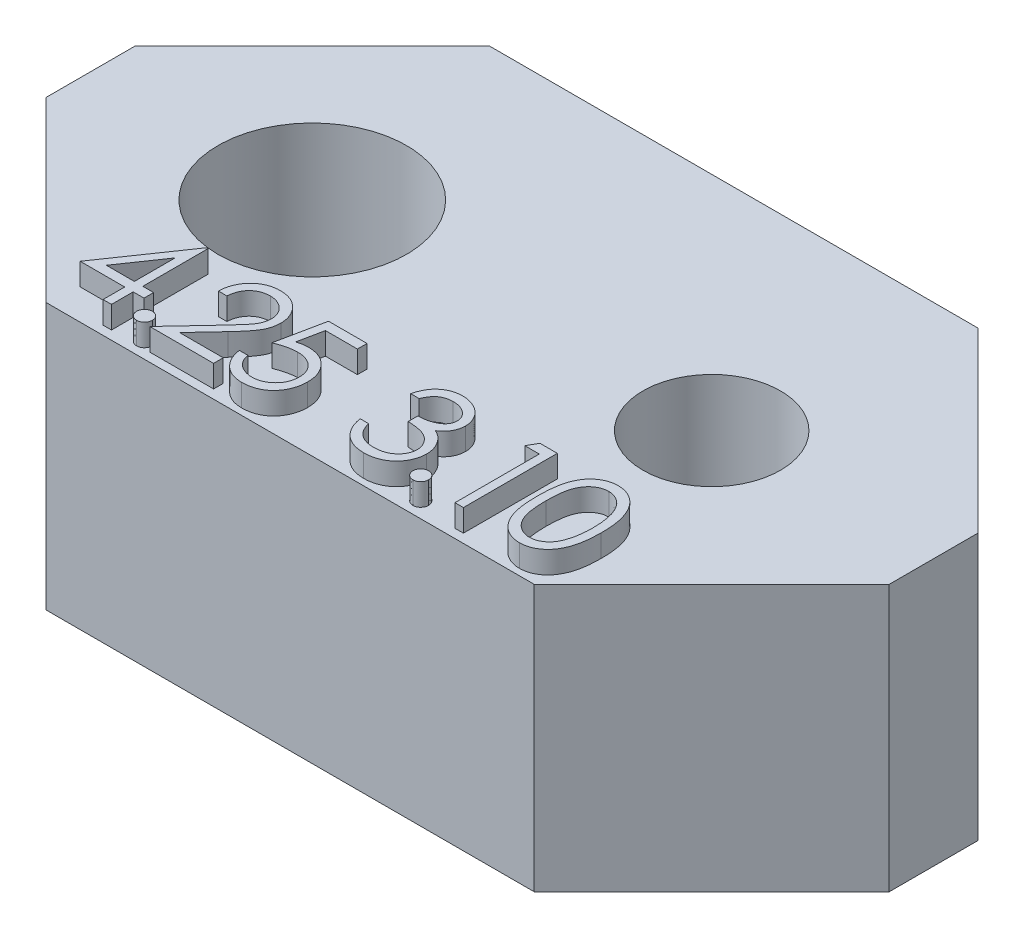
from build123d import *

# Parameters (mm, degrees)
SKETCH_1_R      = 2.125
SKETCH_1_R_2    = 1.55
EXTRUDE_1_DEPTH = 6
SKETCH_1_3_R    = 2.125
SKETCH_1_3_R_2  = 1.55
EXTRUDE_2_DEPTH = 2
EXTRUDE_3_DEPTH = 0.5


with BuildPart() as part:
    # Эскиз1 → Бобышка-Вытянуть1 (new body)
    with BuildSketch(Plane(origin=(0, 0, 0), x_dir=(1, 0, 0), z_dir=(0, 1, 0))):
        Polygon((9.5, 1), (5.5, 5), (-5.5, 5), (-9.5, 1), (-9.5, -1), (-5.5, -5), (5.5, -5), (9.5, -1), align=None)
        with Locations((-4.5, 0)):
            Circle(SKETCH_1_R, mode=Mode.SUBTRACT)
        with Locations((4.5, 0)):
            Circle(SKETCH_1_R_2, mode=Mode.SUBTRACT)
    extrude(amount=EXTRUDE_1_DEPTH)

    # Эскиз1<3> → Бобышка-Вытянуть2 (add)
    with BuildSketch(Plane(origin=(0, 0, 0), x_dir=(1, 0, 0), z_dir=(0, 1, 0))):
        with Locations((-4.5, 0)):
            Circle(SKETCH_1_3_R)
        with Locations((4.5, 0)):
            Circle(SKETCH_1_3_R_2)
    extrude(amount=EXTRUDE_2_DEPTH)

    # Эскиз3 → Бобышка-Вытянуть3 (add)
    # profile 1 of 8: a face of its own
    with BuildSketch(Plane(origin=(0, 6, 0), x_dir=(1, 0, 0), z_dir=(0, 1, 0))):
        Polygon((-4.263157719, -2.629059829), (-4.22457265, -2.629059829), (-4.22457265, -4.094444444), (-3.98034188, -4.094444444), (-3.98034188, -4.311538462), (-4.22457265, -4.311538462), (-4.22457265, -4.8), (-4.414529915, -4.8), (-4.414529915, -4.311538462), (-5.418589744, -4.311538462), align=None)
        Polygon((-4.414529915, -4.094444444), (-4.414529915, -3.175186966), (-5.045459402, -4.094444444), align=None, mode=Mode.SUBTRACT)
    # profile 2 of 8: a face of its own
    with BuildSketch(Plane(origin=(0, 6, 0), x_dir=(1, 0, 0), z_dir=(0, 1, 0))):
        with BuildLine():
            add(Edge.make_bspline(
                [(-3.630277778, -4.474358974), (-3.61849084, -4.475059389), (-3.595383926, -4.476432471), (-3.561977406, -4.48585265), (-3.53174254, -4.502579554), (-3.504811135, -4.524872758), (-3.482612456, -4.551902993), (-3.465289443, -4.581896709), (-3.455951324, -4.61558291), (-3.454588244, -4.638823714), (-3.453888889, -4.650747863)],
                knots=[0, 0, 0, 0, 1.020151414, 1.999887582, 2.974338812, 3.990962822, 5.007586832, 5.987933904, 6.967670073, 8, 8, 8, 8], degree=3))
            add(Edge.make_bspline(
                [(-3.453888889, -4.650747863), (-3.454611943, -4.662385496), (-3.456037794, -4.685334737), (-3.465268038, -4.71876686), (-3.482744478, -4.748779321), (-3.504658021, -4.776176328), (-3.531749198, -4.798516759), (-3.562048886, -4.815101354), (-3.595305504, -4.825196027), (-3.618477757, -4.826481931), (-3.630277778, -4.827136752)],
                knots=[0, 0, 0, 0, 1.009421747, 1.99056486, 2.972319754, 3.999869655, 5.017953583, 5.993804169, 6.978383603, 8, 8, 8, 8], degree=3))
            add(Edge.make_bspline(
                [(-3.630277778, -4.827136752), (-3.642086302, -4.826505624), (-3.665139634, -4.825273498), (-3.698272116, -4.814894086), (-3.72875633, -4.798672279), (-3.755842232, -4.776134672), (-3.777939308, -4.7489203), (-3.794646087, -4.718560166), (-3.804679177, -4.685430439), (-3.80599869, -4.662404346), (-3.806666667, -4.650747863)],
                knots=[0, 0, 0, 0, 1.022052826, 1.995314843, 2.982371812, 4.00089066, 5.028879526, 6.005146991, 6.990147033, 8, 8, 8, 8], degree=3))
            add(Edge.make_bspline(
                [(-3.806666667, -4.650747863), (-3.806024349, -4.638804191), (-3.804770304, -4.615485636), (-3.794625024, -4.582103319), (-3.778068934, -4.551763358), (-3.755689481, -4.524913998), (-3.728762883, -4.502424534), (-3.698345654, -4.486056778), (-3.665059837, -4.476356147), (-3.642072874, -4.475036244), (-3.630277778, -4.474358974)],
                knots=[0, 0, 0, 0, 1.032775665, 2.016367738, 2.991239715, 4.008302682, 5.025365648, 6.011011707, 6.979408107, 8, 8, 8, 8], degree=3))
        make_face()
    # profile 3 of 8: a face of its own
    with BuildSketch(Plane(origin=(0, 6, 0), x_dir=(1, 0, 0), z_dir=(0, 1, 0))):
        with BuildLine():
            Line((-3.09025641, -3.334615385), (-3.280213675, -3.334615385))
            add(Edge.make_bspline(
                [(-3.280213675, -3.334615385), (-3.278975635, -3.309414419), (-3.276544157, -3.259920394), (-3.265157525, -3.187757841), (-3.248864709, -3.118781843), (-3.225828449, -3.053546229), (-3.197219414, -2.991474188), (-3.162911255, -2.932812274), (-3.122274973, -2.877784269), (-3.076188044, -2.826900302), (-3.026132724, -2.7802202), (-2.972123894, -2.739909648), (-2.915369997, -2.705850866), (-2.856043217, -2.677377925), (-2.79347421, -2.656005732), (-2.728230767, -2.640147883), (-2.660026242, -2.63060695), (-2.613556324, -2.629581404), (-2.589922543, -2.629059829)],
                knots=[0, 0, 0, 0, 1.10065271, 2.161652631, 3.183658789, 4.190468796, 5.17591951, 6.163126047, 7.15150782, 8.156236427, 9.156009102, 10.134482811, 11.092018607, 12.041330605, 13.001268258, 13.972401359, 14.968799086, 16, 16, 16, 16], degree=3))
            add(Edge.make_bspline(
                [(-2.589922543, -2.629059829), (-2.566712946, -2.629603181), (-2.521106916, -2.630670849), (-2.454545603, -2.639839662), (-2.391180286, -2.654200091), (-2.331134828, -2.674347986), (-2.274888303, -2.701431901), (-2.222018176, -2.733966603), (-2.171895019, -2.771594787), (-2.126775678, -2.815895903), (-2.085344602, -2.863189726), (-2.04960181, -2.913680029), (-2.018992896, -2.965828217), (-1.993479395, -3.020031938), (-1.974697825, -3.07680156), (-1.960438623, -3.135310583), (-1.952378711, -3.196164635), (-1.951141717, -3.237352886), (-1.950512821, -3.258293269)],
                knots=[0, 0, 0, 0, 1.111607364, 2.184268762, 3.212621178, 4.221274766, 5.211760367, 6.196651075, 7.1921475, 8.207485113, 9.220403448, 10.201281604, 11.166441695, 12.114753415, 13.065576456, 14.026450734, 14.996634279, 16, 16, 16, 16], degree=3))
            add(Edge.make_bspline(
                [(-1.950512821, -3.258293269), (-1.951536841, -3.287774103), (-1.953566913, -3.346218422), (-1.970932274, -3.432103601), (-1.998053736, -3.515314859), (-2.03070928, -3.582284561), (-2.063652139, -3.636249579), (-2.093338394, -3.680680653), (-2.128090922, -3.728520626), (-2.168415538, -3.779609302), (-2.213478084, -3.834346849), (-2.263686726, -3.892700202), (-2.319399498, -3.954066462), (-2.358502496, -3.99597985), (-2.37876469, -4.017698317)],
                knots=[0, 0, 0, 0, 1.184426356, 2.348067706, 3.509069118, 4.696110526, 5.333549288, 6.050745305, 6.844228056, 7.710549037, 8.667450064, 9.695053472, 10.805634456, 12, 12, 12, 12], degree=3))
            Line((-2.37876469, -4.017698317), (-2.908355369, -4.582905983))
            Line((-2.908355369, -4.582905983), (-1.923376068, -4.582905983))
            Line((-1.923376068, -4.582905983), (-1.923376068, -4.8))
            Line((-1.923376068, -4.8), (-3.361623932, -4.8))
            Line((-3.361623932, -4.8), (-2.540737179, -3.92399172))
            add(Edge.make_bspline(
                [(-2.540737179, -3.92399172), (-2.520751077, -3.903128459), (-2.482361863, -3.863054403), (-2.428064781, -3.804547946), (-2.379297393, -3.750270843), (-2.335744017, -3.700325644), (-2.298349469, -3.653981791), (-2.265164833, -3.612740233), (-2.238576118, -3.574788732), (-2.209719665, -3.53079798), (-2.181771209, -3.477087673), (-2.157754689, -3.411450633), (-2.143110472, -3.343882247), (-2.141353738, -3.298221491), (-2.140470085, -3.275253739)],
                knots=[0, 0, 0, 0, 1.329631726, 2.553950428, 3.673215718, 4.687767853, 5.603093632, 6.413772471, 7.123043292, 7.734684054, 8.834405432, 9.900288307, 10.943827018, 12, 12, 12, 12], degree=3))
            add(Edge.make_bspline(
                [(-2.140470085, -3.275253739), (-2.140854558, -3.260811179), (-2.14161228, -3.232347667), (-2.148299554, -3.190615613), (-2.158405432, -3.150359749), (-2.172886612, -3.111456251), (-2.192001164, -3.074296261), (-2.215268399, -3.038834547), (-2.242113818, -3.004551221), (-2.273169109, -2.972406131), (-2.307284647, -2.942965592), (-2.343324979, -2.916885788), (-2.38145528, -2.895090707), (-2.421514783, -2.877223925), (-2.463391805, -2.863208338), (-2.507167341, -2.85349672), (-2.552720437, -2.847399218), (-2.583825456, -2.846574219), (-2.599674813, -2.846153846)],
                knots=[0, 0, 0, 0, 0.991446411, 1.95395049, 2.89581595, 3.838931463, 4.798493298, 5.75982156, 6.748411868, 7.785213223, 8.824556874, 9.840280684, 10.836137867, 11.835679398, 12.848801643, 13.863922112, 14.911575587, 16, 16, 16, 16], degree=3))
            add(Edge.make_bspline(
                [(-2.599674813, -2.846153846), (-2.61622765, -2.84658627), (-2.648734689, -2.84743548), (-2.696461913, -2.853375853), (-2.741991884, -2.863624052), (-2.78543913, -2.877640422), (-2.826877165, -2.89545583), (-2.866104468, -2.917645599), (-2.903032977, -2.944124188), (-2.937732112, -2.974144905), (-2.969702233, -3.007568645), (-2.997791534, -3.044828004), (-3.0223352, -3.085242679), (-3.043749355, -3.128703621), (-3.061139701, -3.175605193), (-3.074428226, -3.2257809), (-3.084943128, -3.279012878), (-3.0884559, -3.315773382), (-3.09025641, -3.334615385)],
                knots=[0, 0, 0, 0, 1.031018746, 2.02475058, 2.990194455, 3.934040569, 4.864654155, 5.795059489, 6.735614925, 7.690564532, 8.649604399, 9.611025574, 10.590972636, 11.591080095, 12.624614302, 13.701020113, 14.821632451, 16, 16, 16, 16], degree=3))
        make_face()
    # profile 4 of 8: a face of its own
    with BuildSketch(Plane(origin=(0, 6, 0), x_dir=(1, 0, 0), z_dir=(0, 1, 0))):
        with BuildLine():
            Line((-0.582820513, -2.683333333), (-0.582820513, -2.90042735))
            Line((-0.582820513, -2.90042735), (-1.302792468, -2.90042735))
            Line((-1.302792468, -2.90042735), (-1.416851629, -3.457154781))
            add(Edge.make_bspline(
                [(-1.416851629, -3.457154781), (-1.394441648, -3.450967902), (-1.351025854, -3.438981803), (-1.286945367, -3.425673552), (-1.226111034, -3.417651117), (-1.186634977, -3.416555705), (-1.167532719, -3.416025641)],
                knots=[0, 0, 0, 0, 1.100273476, 2.13160584, 3.095893838, 4, 4, 4, 4], degree=3))
            add(Edge.make_bspline(
                [(-1.167532719, -3.416025641), (-1.143896362, -3.416537231), (-1.097421379, -3.417543144), (-1.029422587, -3.42720231), (-0.964511742, -3.442405973), (-0.902824595, -3.463645526), (-0.844247024, -3.490805222), (-0.789317974, -3.524732329), (-0.737212951, -3.564364391), (-0.688866715, -3.609930184), (-0.645006777, -3.660078019), (-0.606443535, -3.713997303), (-0.573688064, -3.771164032), (-0.547344179, -3.8321244), (-0.526307939, -3.896204459), (-0.512306494, -3.96407845), (-0.502983056, -4.035106598), (-0.501941422, -4.083671743), (-0.501410256, -4.108436832)],
                knots=[0, 0, 0, 0, 1.052922333, 2.070308379, 3.05430497, 4.020497103, 4.973039431, 5.925935799, 6.892292201, 7.88610001, 8.88166317, 9.857072816, 10.836096531, 11.812156883, 12.81219415, 13.836441305, 14.89672472, 16, 16, 16, 16], degree=3))
            add(Edge.make_bspline(
                [(-0.501410256, -4.108436832), (-0.501812469, -4.125685985), (-0.502611457, -4.159951182), (-0.506674603, -4.210838389), (-0.514497632, -4.260648293), (-0.525000969, -4.309387501), (-0.538633765, -4.35696374), (-0.555137145, -4.403513188), (-0.575333791, -4.448746117), (-0.597487051, -4.493090523), (-0.622431349, -4.535543906), (-0.650116447, -4.575245912), (-0.679366053, -4.61279212), (-0.710838701, -4.647779854), (-0.744826922, -4.679979203), (-0.780919092, -4.709581259), (-0.818827213, -4.737086635), (-0.859137764, -4.761378829), (-0.900952504, -4.783732617), (-0.944875283, -4.802071137), (-0.989906278, -4.818466552), (-1.036693607, -4.831535171), (-1.085131294, -4.841775335), (-1.135299182, -4.84873046), (-1.186934158, -4.85379621), (-1.221934761, -4.854113321), (-1.239614717, -4.854273504)],
                knots=[0, 0, 0, 0, 1.056347294, 2.098418968, 3.122841568, 4.141288669, 5.149314143, 6.15115421, 7.162517403, 8.180376062, 9.185164535, 10.17417709, 11.141909838, 12.097768115, 13.052685741, 14.0056014, 14.954263652, 15.917497458, 16.885230207, 17.854509472, 18.828990115, 19.81800267, 20.826176721, 21.857883937, 22.917946725, 24, 24, 24, 24], degree=3))
            add(Edge.make_bspline(
                [(-1.239614717, -4.854273504), (-1.260705293, -4.853855712), (-1.302198509, -4.853033754), (-1.362989519, -4.844434956), (-1.421478828, -4.832119635), (-1.477195604, -4.813591986), (-1.530639177, -4.790376813), (-1.581090059, -4.761036081), (-1.629837362, -4.727786813), (-1.674899403, -4.688549647), (-1.716722386, -4.645662544), (-1.754161084, -4.599121495), (-1.787503771, -4.549694642), (-1.816216504, -4.497141948), (-1.840708164, -4.441601504), (-1.859948657, -4.382865213), (-1.875477948, -4.321239972), (-1.882047731, -4.278813801), (-1.885384615, -4.257264957)],
                knots=[0, 0, 0, 0, 1.0467383, 2.05933395, 3.04377827, 4.011590433, 4.970194871, 5.932262533, 6.905835911, 7.896367577, 8.894135286, 9.877477877, 10.858688626, 11.851381753, 12.8477658, 13.868841284, 14.917554742, 16, 16, 16, 16], degree=3))
            Line((-1.885384615, -4.257264957), (-1.69542735, -4.257264957))
            add(Edge.make_bspline(
                [(-1.69542735, -4.257264957), (-1.690753413, -4.277449764), (-1.681769847, -4.316246084), (-1.662051132, -4.370754086), (-1.637941769, -4.419328092), (-1.609273425, -4.46261065), (-1.575074121, -4.500353234), (-1.536049181, -4.533988314), (-1.492296034, -4.564332321), (-1.443677271, -4.589625137), (-1.392385552, -4.611196241), (-1.338702525, -4.625560361), (-1.284089896, -4.635660425), (-1.247152025, -4.636671442), (-1.228590411, -4.637179487)],
                knots=[0, 0, 0, 0, 1.136247022, 2.183929868, 3.172523383, 4.106158343, 5.02341133, 5.958108904, 6.928429099, 7.938127109, 8.96079061, 9.975095812, 10.982467395, 12, 12, 12, 12], degree=3))
            add(Edge.make_bspline(
                [(-1.228590411, -4.637179487), (-1.210472685, -4.636683112), (-1.174798735, -4.635705745), (-1.122298515, -4.628183104), (-1.071611682, -4.616597335), (-1.023238376, -4.599258899), (-0.976332111, -4.578186141), (-0.932079402, -4.551144166), (-0.889200043, -4.520023108), (-0.849026839, -4.484368384), (-0.812233458, -4.445077187), (-0.779723803, -4.403059907), (-0.752644432, -4.358236861), (-0.72982428, -4.31138405), (-0.712495857, -4.26198797), (-0.70013393, -4.210280116), (-0.692874937, -4.156132771), (-0.691876367, -4.119200379), (-0.691367521, -4.100380609)],
                knots=[0, 0, 0, 0, 1.027316725, 2.022795036, 3.002884548, 3.971462791, 4.93288096, 5.914575861, 6.907176829, 7.935150275, 8.956128384, 9.956726525, 10.942570165, 11.921478529, 12.907843606, 13.90538589, 14.932640048, 16, 16, 16, 16], degree=3))
            add(Edge.make_bspline(
                [(-0.691367521, -4.100380609), (-0.691765745, -4.083401464), (-0.69254521, -4.050167203), (-0.698913698, -4.001544826), (-0.709991105, -3.955538748), (-0.725366499, -3.911926807), (-0.744887916, -3.870667868), (-0.768743543, -3.83171935), (-0.797381074, -3.795594604), (-0.830093787, -3.762276726), (-0.865930793, -3.731527683), (-0.905508675, -3.70531483), (-0.947999203, -3.683262842), (-0.992890437, -3.664232195), (-1.041250161, -3.650564126), (-1.092120696, -3.640302595), (-1.146051371, -3.634366637), (-1.182924121, -3.633543019), (-1.201877671, -3.633119658)],
                knots=[0, 0, 0, 0, 1.045622112, 2.046656509, 3.013763289, 3.955457236, 4.890082067, 5.820317437, 6.762574623, 7.722996705, 8.69280354, 9.665887285, 10.63943826, 11.638615906, 12.663482002, 13.728887084, 14.832589034, 16, 16, 16, 16], degree=3))
            add(Edge.make_bspline(
                [(-1.201877671, -3.633119658), (-1.218284214, -3.633470778), (-1.252159562, -3.63419575), (-1.304122414, -3.639533679), (-1.358727409, -3.648145062), (-1.415765223, -3.659990078), (-1.475407149, -3.675490777), (-1.537527325, -3.694065737), (-1.602256362, -3.716273803), (-1.645870414, -3.733045189), (-1.668290598, -3.741666667)],
                knots=[0, 0, 0, 0, 0.817624296, 1.688186739, 2.600797293, 3.572016777, 4.590301741, 5.671205678, 6.80286297, 8, 8, 8, 8], degree=3))
            Line((-1.668290598, -3.741666667), (-1.451196581, -2.683333333))
            Line((-1.451196581, -2.683333333), (-0.582820513, -2.683333333))
        make_face()
    # profile 5 of 8: a face of its own
    with BuildSketch(Plane(origin=(0, 6, 0), x_dir=(1, 0, 0), z_dir=(0, 1, 0))):
        with BuildLine():
            Line((1.077948718, -3.171794872), (0.887991453, -3.171794872))
            add(Edge.make_bspline(
                [(0.887991453, -3.171794872), (0.893137705, -3.150487608), (0.903198207, -3.108833649), (0.924181978, -3.049320687), (0.947041527, -2.993003128), (0.974491128, -2.940935503), (1.004432137, -2.892071405), (1.038735878, -2.847519125), (1.07581971, -2.806145569), (1.116837656, -2.769428516), (1.159853561, -2.73618008), (1.205473545, -2.707831831), (1.252779771, -2.683445319), (1.302099999, -2.663354989), (1.353581065, -2.648220505), (1.406757551, -2.637239961), (1.461768811, -2.630109144), (1.499111402, -2.629413207), (1.518072917, -2.629059829)],
                knots=[0, 0, 0, 0, 1.162005537, 2.271625781, 3.343758855, 4.383309926, 5.390229558, 6.379919256, 7.361854164, 8.333198761, 9.295911338, 10.242430842, 11.177959212, 12.116337295, 13.062827104, 14.020064771, 14.994644689, 16, 16, 16, 16], degree=3))
            add(Edge.make_bspline(
                [(1.518072917, -2.629059829), (1.545700099, -2.629893935), (1.600351834, -2.631543953), (1.680641867, -2.646611255), (1.75806761, -2.670454073), (1.831781584, -2.703397708), (1.900251779, -2.744030035), (1.961173187, -2.792389662), (2.013720048, -2.847543525), (2.057803791, -2.908462743), (2.092320576, -2.973568693), (2.117772811, -3.040576408), (2.133267828, -3.109326933), (2.135275974, -3.155746811), (2.136282051, -3.179003072)],
                knots=[0, 0, 0, 0, 1.083050992, 2.142477498, 3.193116406, 4.255571735, 5.30263384, 6.308962982, 7.297363603, 8.282367274, 9.249857812, 10.179914175, 11.08814088, 12, 12, 12, 12], degree=3))
            add(Edge.make_bspline(
                [(2.136282051, -3.179003072), (2.135578356, -3.201383371), (2.134201333, -3.245178145), (2.122509044, -3.309114479), (2.102832352, -3.369373923), (2.075575876, -3.426210149), (2.040293129, -3.47926279), (1.997552975, -3.52865121), (1.947053746, -3.574594463), (1.908785055, -3.600913382), (1.8890832, -3.614463141)],
                knots=[0, 0, 0, 0, 1.024540389, 2.004866551, 2.965041327, 3.920577974, 4.882998113, 5.874504559, 6.905732034, 8, 8, 8, 8], degree=3))
            add(Edge.make_bspline(
                [(1.8890832, -3.614463141), (1.911599547, -3.625335654), (1.956210942, -3.646877248), (2.017020072, -3.689123349), (2.072221454, -3.737901235), (2.103006084, -3.775966554), (2.118473558, -3.795092147)],
                knots=[0, 0, 0, 0, 1.015518401, 2.012035669, 3.001164323, 4, 4, 4, 4], degree=3))
            add(Edge.make_bspline(
                [(2.118473558, -3.795092147), (2.12865856, -3.809036597), (2.148861778, -3.836697147), (2.173799458, -3.881169176), (2.196423065, -3.926134124), (2.214052007, -3.972797193), (2.227703822, -4.02061754), (2.23746228, -4.069677275), (2.243524498, -4.12001646), (2.244392665, -4.154072102), (2.24482906, -4.171190572)],
                knots=[0, 0, 0, 0, 1.025084078, 2.033381695, 3.024893161, 4.013698104, 4.991890475, 5.976764909, 6.982997093, 8, 8, 8, 8], degree=3))
            add(Edge.make_bspline(
                [(2.24482906, -4.171190572), (2.243743806, -4.200829784), (2.241578407, -4.259968726), (2.222223562, -4.347341534), (2.192219364, -4.432749338), (2.149609693, -4.514437455), (2.097680295, -4.590867495), (2.035899437, -4.659251739), (1.964969085, -4.718033752), (1.885862812, -4.767146604), (1.800157691, -4.80640649), (1.708490548, -4.833655515), (1.612182182, -4.851402858), (1.546137768, -4.853305964), (1.512560764, -4.854273504)],
                knots=[0, 0, 0, 0, 0.955779014, 1.907060117, 2.875433937, 3.871313158, 4.872415639, 5.851225146, 6.836215519, 7.83643374, 8.849228613, 9.86973379, 10.916971861, 12, 12, 12, 12], degree=3))
            add(Edge.make_bspline(
                [(1.512560764, -4.854273504), (1.489930997, -4.853748442), (1.445403161, -4.852715294), (1.379941616, -4.845652521), (1.317456589, -4.832752947), (1.257863594, -4.815394281), (1.201109691, -4.793385942), (1.147368065, -4.76597892), (1.096308082, -4.733738154), (1.048411574, -4.69628308), (1.003684249, -4.654384365), (0.963314745, -4.607298201), (0.926630013, -4.55589501), (0.894612322, -4.499577733), (0.865803307, -4.439074172), (0.842108157, -4.373609604), (0.821252599, -4.303769267), (0.811556171, -4.255099396), (0.806581197, -4.230128205)],
                knots=[0, 0, 0, 0, 1.048658725, 2.063410685, 3.046034179, 4.001477787, 4.936774919, 5.862367409, 6.792675028, 7.730719943, 8.675894397, 9.627829632, 10.600096036, 11.597688215, 12.626045268, 13.701542398, 14.82072376, 16, 16, 16, 16], degree=3))
            Line((0.806581197, -4.230128205), (0.996538462, -4.230128205))
            add(Edge.make_bspline(
                [(0.996538462, -4.230128205), (1.001487404, -4.246425942), (1.011113528, -4.278126455), (1.027499128, -4.323749878), (1.046167083, -4.365574034), (1.066193506, -4.403905732), (1.087226185, -4.43912247), (1.11076045, -4.470293029), (1.135053218, -4.498786509), (1.153365018, -4.514839679), (1.162327057, -4.522696314)],
                knots=[0, 0, 0, 0, 1.198163088, 2.33053128, 3.407730985, 4.417276592, 5.372219308, 6.28897303, 7.162600585, 8, 8, 8, 8], degree=3))
            add(Edge.make_bspline(
                [(1.162327057, -4.522696314), (1.17417832, -4.531833259), (1.197844263, -4.550078945), (1.23640886, -4.573363263), (1.276967148, -4.59353874), (1.320397928, -4.608950309), (1.365764003, -4.621999656), (1.413798648, -4.630539208), (1.464078079, -4.636398245), (1.49840906, -4.636915275), (1.515952858, -4.637179487)],
                knots=[0, 0, 0, 0, 0.946170439, 1.889420265, 2.845303464, 3.807233317, 4.801018734, 5.828864929, 6.890507805, 8, 8, 8, 8], degree=3))
            add(Edge.make_bspline(
                [(1.515952858, -4.637179487), (1.535760929, -4.636807011), (1.574493901, -4.636078666), (1.631011839, -4.629380501), (1.684779677, -4.619625441), (1.735200446, -4.604559018), (1.78293461, -4.585943932), (1.827313036, -4.562570849), (1.868918301, -4.535148088), (1.907217512, -4.503979169), (1.941655986, -4.469857598), (1.971978454, -4.434168741), (1.997756225, -4.397063072), (2.018550103, -4.358335256), (2.034969722, -4.318145666), (2.046147657, -4.276381516), (2.053919764, -4.233384598), (2.054552715, -4.204157079), (2.054871795, -4.189423077)],
                knots=[0, 0, 0, 0, 1.217147791, 2.380027433, 3.494444702, 4.572153297, 5.609568379, 6.639424714, 7.649109417, 8.668170816, 9.669597737, 10.625200337, 11.543417969, 12.441394052, 13.322311151, 14.205496177, 15.095365482, 16, 16, 16, 16], degree=3))
            add(Edge.make_bspline(
                [(2.054871795, -4.189423077), (2.053946327, -4.169700982), (2.052099996, -4.130354925), (2.038003855, -4.072468583), (2.01481797, -4.016695376), (1.98235888, -3.963986874), (1.94284632, -3.915136686), (1.896663734, -3.871550599), (1.843427615, -3.835585354), (1.794429884, -3.8107365), (1.751029052, -3.793780745), (1.713887367, -3.782486838), (1.672305992, -3.772923341), (1.626787772, -3.76402592), (1.576989731, -3.756453485), (1.522966086, -3.750138673), (1.464705887, -3.745085862), (1.42437361, -3.742829438), (1.403589744, -3.741666667)],
                knots=[0, 0, 0, 0, 1.07054697, 2.135767047, 3.216561865, 4.33974944, 5.486079747, 6.621378074, 7.775625952, 8.963672916, 9.598146892, 10.304877434, 11.070270905, 11.915000392, 12.823868403, 13.805723172, 14.86925407, 16, 16, 16, 16], degree=3))
            Line((1.403589744, -3.741666667), (1.403589744, -3.52457265))
            add(Edge.make_bspline(
                [(1.403589744, -3.52457265), (1.429776639, -3.524128268), (1.481070334, -3.523257834), (1.55599689, -3.512730133), (1.627645036, -3.498167086), (1.694426923, -3.475860327), (1.75529543, -3.449952148), (1.808102999, -3.419803431), (1.852109798, -3.386290701), (1.88710197, -3.348896695), (1.913426789, -3.30879188), (1.932674424, -3.266992759), (1.944044145, -3.223132969), (1.945561896, -3.19320048), (1.946324786, -3.178155048)],
                knots=[0, 0, 0, 0, 1.321986639, 2.589447074, 3.816329219, 5.01088745, 6.139805852, 7.153945165, 8.075214402, 8.924034688, 9.728124013, 10.488707548, 11.240355623, 12, 12, 12, 12], degree=3))
            add(Edge.make_bspline(
                [(1.946324786, -3.178155048), (1.946074166, -3.167101364), (1.94557557, -3.145110584), (1.939287692, -3.112982566), (1.929838868, -3.081836756), (1.916848746, -3.051805604), (1.899461721, -3.023097391), (1.878654291, -2.995467362), (1.853878344, -2.969073267), (1.825487526, -2.94447136), (1.795000387, -2.921025202), (1.761587428, -2.901120288), (1.726256104, -2.884099227), (1.688967298, -2.870063004), (1.649600001, -2.859504292), (1.608339178, -2.851923093), (1.565106151, -2.847183178), (1.535610865, -2.846500755), (1.520616987, -2.846153846)],
                knots=[0, 0, 0, 0, 0.884392785, 1.759457502, 2.611959086, 3.489218968, 4.37281399, 5.2945488, 6.255912374, 7.266815255, 8.301784654, 9.332968512, 10.37626691, 11.440494194, 12.520033166, 13.637162961, 14.798855837, 16, 16, 16, 16], degree=3))
            add(Edge.make_bspline(
                [(1.520616987, -2.846153846), (1.496516217, -2.846995289), (1.449441806, -2.848638822), (1.381578499, -2.863033978), (1.31849014, -2.886001676), (1.270267232, -2.913417359), (1.234657294, -2.940480717), (1.209210765, -2.964116255), (1.184221695, -2.990382773), (1.161334071, -3.020898076), (1.138187428, -3.053595611), (1.117114765, -3.090137551), (1.096637713, -3.129570685), (1.084299028, -3.157447569), (1.077948718, -3.171794872)],
                knots=[0, 0, 0, 0, 1.472543308, 2.876219568, 4.221790263, 5.565193594, 6.249813518, 6.953379497, 7.687249741, 8.463570142, 9.283606569, 10.136032583, 11.040678096, 12, 12, 12, 12], degree=3))
        make_face()
    # profile 6 of 8: a face of its own
    with BuildSketch(Plane(origin=(0, 6, 0), x_dir=(1, 0, 0), z_dir=(0, 1, 0))):
        with BuildLine():
            add(Edge.make_bspline(
                [(2.594893162, -4.474358974), (2.6066801, -4.475059389), (2.629787014, -4.476432471), (2.663193534, -4.48585265), (2.6934284, -4.502579554), (2.720359805, -4.524872758), (2.742558484, -4.551902993), (2.759881497, -4.581896709), (2.769219616, -4.61558291), (2.770582696, -4.638823714), (2.771282051, -4.650747863)],
                knots=[0, 0, 0, 0, 1.020151414, 1.999887582, 2.974338812, 3.990962822, 5.007586832, 5.987933904, 6.967670073, 8, 8, 8, 8], degree=3))
            add(Edge.make_bspline(
                [(2.771282051, -4.650747863), (2.770558997, -4.662385496), (2.769133146, -4.685334737), (2.759902902, -4.71876686), (2.742426462, -4.748779321), (2.720512919, -4.776176328), (2.693421742, -4.798516759), (2.663122054, -4.815101354), (2.629865436, -4.825196027), (2.606693184, -4.826481931), (2.594893162, -4.827136752)],
                knots=[0, 0, 0, 0, 1.009421747, 1.99056486, 2.972319754, 3.999869655, 5.017953583, 5.993804169, 6.978383603, 8, 8, 8, 8], degree=3))
            add(Edge.make_bspline(
                [(2.594893162, -4.827136752), (2.583084638, -4.826505624), (2.560031307, -4.825273498), (2.526898824, -4.814894086), (2.49641461, -4.798672279), (2.469328708, -4.776134672), (2.447231633, -4.7489203), (2.430524853, -4.718560166), (2.420491763, -4.685430439), (2.41917225, -4.662404346), (2.418504274, -4.650747863)],
                knots=[0, 0, 0, 0, 1.022052826, 1.995314843, 2.982371812, 4.00089066, 5.028879526, 6.005146991, 6.990147033, 8, 8, 8, 8], degree=3))
            add(Edge.make_bspline(
                [(2.418504274, -4.650747863), (2.419146591, -4.638804191), (2.420400636, -4.615485636), (2.430545916, -4.582103319), (2.447102006, -4.551763358), (2.46948146, -4.524913998), (2.496408058, -4.502424534), (2.526825286, -4.486056778), (2.560111104, -4.476356147), (2.583098066, -4.475036244), (2.594893162, -4.474358974)],
                knots=[0, 0, 0, 0, 1.032775665, 2.016367738, 2.991239715, 4.008302682, 5.025365648, 6.011011707, 6.979408107, 8, 8, 8, 8], degree=3))
        make_face()
    # profile 7 of 8: a face of its own
    with BuildSketch(Plane(origin=(0, 6, 0), x_dir=(1, 0, 0), z_dir=(0, 1, 0))):
        Polygon((3.313423478, -2.683333333), (3.704786325, -2.683333333), (3.704786325, -4.8), (3.51482906, -4.8), (3.51482906, -2.90042735), (3.189188034, -2.90042735), align=None)
    # profile 8 of 8: a face of its own
    with BuildSketch(Plane(origin=(0, 6, 0), x_dir=(1, 0, 0), z_dir=(0, 1, 0))):
        with BuildLine():
            add(Edge.make_bspline(
                [(4.312649573, -3.74251469), (4.312847946, -3.708589127), (4.313233288, -3.642688232), (4.317520095, -3.546661329), (4.324641373, -3.456575821), (4.334400641, -3.372427396), (4.346276944, -3.294194328), (4.362131071, -3.22208569), (4.380160719, -3.155767737), (4.401056722, -3.095024212), (4.424635051, -3.039036744), (4.450297676, -2.986770075), (4.479063051, -2.938303287), (4.509287184, -2.892862814), (4.542193532, -2.851192484), (4.576845658, -2.812703827), (4.614596031, -2.778286373), (4.654161374, -2.746931704), (4.695899902, -2.719445595), (4.738621896, -2.69523532), (4.782621412, -2.674552543), (4.82801858, -2.658290232), (4.874405365, -2.644857958), (4.921943924, -2.635672261), (4.970712749, -2.629892607), (5.003630807, -2.629340055), (5.020325187, -2.629059829)],
                knots=[0, 0, 0, 0, 1.646270934, 3.197905019, 4.663502075, 6.030701355, 7.308322542, 8.50163776, 9.611534131, 10.641858119, 11.616356847, 12.558055219, 13.465016945, 14.349605745, 15.204443733, 16.039544428, 16.859896111, 17.680448484, 18.487036065, 19.28249412, 20.06191084, 20.843045899, 21.620316918, 22.403196591, 23.190181807, 24, 24, 24, 24], degree=3))
            add(Edge.make_bspline(
                [(5.020325187, -2.629059829), (5.037159024, -2.629354841), (5.070636229, -2.629941527), (5.120130171, -2.635580292), (5.168480692, -2.644936638), (5.215481662, -2.658193609), (5.261519154, -2.674640518), (5.306233076, -2.695255108), (5.349901169, -2.719251375), (5.391829485, -2.74744772), (5.432478324, -2.77888462), (5.470849235, -2.814422044), (5.506945711, -2.85370116), (5.541220777, -2.896301716), (5.572702019, -2.943040791), (5.602682142, -2.993105467), (5.629516659, -3.047371275), (5.655360963, -3.104932796), (5.677668807, -3.167382723), (5.697786965, -3.234369031), (5.714042341, -3.306682944), (5.72758252, -3.383945054), (5.738072052, -3.466439104), (5.745711793, -3.553988256), (5.749747421, -3.646650112), (5.750507426, -3.710003668), (5.750897436, -3.74251469)],
                knots=[0, 0, 0, 0, 0.810914788, 1.612654377, 2.396697861, 3.181598691, 3.963628158, 4.749916497, 5.551656086, 6.361998678, 7.18212741, 8.025565596, 8.878627764, 9.750805457, 10.657531673, 11.591944965, 12.560506719, 13.57287815, 14.630710178, 15.753379473, 16.941251878, 18.199788006, 19.531962791, 20.947069417, 22.433333509, 24, 24, 24, 24], degree=3))
            add(Edge.make_bspline(
                [(5.750897436, -3.74251469), (5.750503382, -3.774883911), (5.749735585, -3.837954017), (5.745757034, -3.93019894), (5.737920147, -4.017283471), (5.728116964, -4.099416465), (5.714539477, -4.176256072), (5.697844924, -4.248068191), (5.679308776, -4.315162939), (5.656427734, -4.376990659), (5.631384114, -4.434413844), (5.604136448, -4.488036357), (5.574944696, -4.538332163), (5.543141026, -4.584898676), (5.509242057, -4.628065769), (5.472522252, -4.667071474), (5.434016708, -4.702855642), (5.393248247, -4.734697341), (5.350666023, -4.762567675), (5.307147914, -4.787492242), (5.261921773, -4.80759011), (5.216012511, -4.824847015), (5.168763451, -4.838031098), (5.120233491, -4.847147192), (5.070669482, -4.853540643), (5.037164726, -4.854028371), (5.020325187, -4.854273504)],
                knots=[0, 0, 0, 0, 1.561518951, 3.042555995, 4.452378317, 5.7783523, 7.031515105, 8.214008947, 9.334062868, 10.386615937, 11.391082383, 12.354592575, 13.286541444, 14.194233754, 15.072674879, 15.931287219, 16.775624067, 17.606195743, 18.42308326, 19.229000347, 20.022332153, 20.807536673, 21.593273796, 22.3848459, 23.188221202, 24, 24, 24, 24], degree=3))
            add(Edge.make_bspline(
                [(5.020325187, -4.854273504), (5.00363127, -4.85399147), (4.970714125, -4.853435354), (4.921938611, -4.847681812), (4.874596371, -4.838431674), (4.828453792, -4.825479728), (4.783274137, -4.809625994), (4.73967305, -4.788971147), (4.697165736, -4.7651834), (4.655865605, -4.738092836), (4.616548726, -4.707055437), (4.578993855, -4.672726558), (4.544144439, -4.634249542), (4.511708581, -4.592231941), (4.480881395, -4.547060314), (4.452524488, -4.498117917), (4.426295448, -4.445598814), (4.402320575, -4.389163697), (4.381064002, -4.32798905), (4.362287531, -4.261375023), (4.347462302, -4.188733662), (4.33477261, -4.110648397), (4.324537388, -4.026783687), (4.317549772, -3.937094002), (4.313230977, -3.841635233), (4.312846911, -3.776157798), (4.312649573, -3.74251469)],
                knots=[0, 0, 0, 0, 0.810891512, 1.598919785, 2.382837074, 3.152667961, 3.926044502, 4.706494248, 5.493654104, 6.291793342, 7.103789334, 7.925228297, 8.761435821, 9.622817696, 10.50288917, 11.416980706, 12.369136599, 13.353924996, 14.394355917, 15.514179734, 16.714354668, 17.994756427, 19.357759367, 20.818452758, 22.365282078, 24, 24, 24, 24], degree=3))
        make_face()
        with BuildLine():
            add(Edge.make_bspline(
                [(4.502606838, -3.741666667), (4.502679075, -3.769938499), (4.502819273, -3.824808574), (4.506481832, -3.904542355), (4.511471258, -3.978910125), (4.517906709, -4.048006312), (4.52746373, -4.111597034), (4.538172121, -4.170119651), (4.551203585, -4.223264457), (4.566622, -4.271396133), (4.58418374, -4.315331522), (4.603358238, -4.356214161), (4.623956866, -4.394526999), (4.647009876, -4.429925896), (4.672116605, -4.46252629), (4.698709957, -4.492905194), (4.727782424, -4.519996701), (4.768001354, -4.552488656), (4.821097318, -4.586064514), (4.887996355, -4.615302387), (4.956738704, -4.633676539), (5.003396841, -4.636013192), (5.026685363, -4.637179487)],
                knots=[0, 0, 0, 0, 1.459021318, 2.831673884, 4.118529203, 5.306027144, 6.411944654, 7.436330062, 8.375795394, 9.233974572, 10.042671642, 10.816086306, 11.563610507, 12.285937304, 12.993564865, 13.685989202, 14.367179055, 15.041617293, 16.353048772, 17.594441528, 18.799311195, 20, 20, 20, 20], degree=3))
            add(Edge.make_bspline(
                [(5.026685363, -4.637179487), (5.050124527, -4.63621321), (5.09695446, -4.634282651), (5.16537347, -4.615656748), (5.231794633, -4.587553741), (5.283847663, -4.554323583), (5.323449011, -4.522677403), (5.351822619, -4.495696163), (5.377864906, -4.465484758), (5.402564637, -4.432888517), (5.425218459, -4.397284681), (5.445818547, -4.358844457), (5.464616571, -4.317461097), (5.475326328, -4.288571779), (5.48080195, -4.273801416)],
                knots=[0, 0, 0, 0, 1.353760809, 2.704726607, 4.075137775, 5.516104923, 6.260822281, 7.007110065, 7.778089737, 8.566572457, 9.372053459, 10.217411131, 11.088608312, 12, 12, 12, 12], degree=3))
            add(Edge.make_bspline(
                [(5.48080195, -4.273801416), (5.487183257, -4.254914859), (5.500140047, -4.216567049), (5.516838596, -4.157080459), (5.529989385, -4.094667359), (5.541820564, -4.029700741), (5.549895983, -3.961701493), (5.556395851, -3.890880014), (5.56022441, -3.817182904), (5.560698997, -3.767111648), (5.560940171, -3.741666667)],
                knots=[0, 0, 0, 0, 0.884706709, 1.796334032, 2.740027952, 3.714592787, 4.726048262, 5.777819803, 6.87074269, 8, 8, 8, 8], degree=3))
            add(Edge.make_bspline(
                [(5.560940171, -3.741666667), (5.560607437, -3.716225801), (5.55995654, -3.66645803), (5.557468557, -3.593573226), (5.551043823, -3.524347485), (5.543908166, -3.45848258), (5.533386989, -3.396343111), (5.522042982, -3.337408879), (5.506802249, -3.282410002), (5.490522195, -3.230485398), (5.471889241, -3.182225002), (5.451378297, -3.137403807), (5.429472757, -3.095805426), (5.405680069, -3.05754399), (5.38028268, -3.022448119), (5.352610257, -2.991221483), (5.32376047, -2.962896269), (5.283351981, -2.930564144), (5.230450863, -2.897597547), (5.164625162, -2.867259207), (5.096123392, -2.849837049), (5.049814684, -2.847380695), (5.026685363, -2.846153846)],
                knots=[0, 0, 0, 0, 1.31362396, 2.569729283, 3.763502607, 4.902122613, 5.988968491, 7.01645872, 7.998833611, 8.933434873, 9.825090667, 10.667526885, 11.477055099, 12.250526234, 12.991942729, 13.710640831, 14.402115721, 15.076753259, 16.378508321, 17.609869233, 18.806226677, 20, 20, 20, 20], degree=3))
            add(Edge.make_bspline(
                [(5.026685363, -2.846153846), (5.003274672, -2.847382388), (4.95641064, -2.849841709), (4.887196877, -2.867194296), (4.820851865, -2.897440232), (4.768090637, -2.930673334), (4.727653966, -2.96232555), (4.699180147, -2.989773549), (4.672482224, -3.019797712), (4.647887948, -3.052697918), (4.624853, -3.088055545), (4.603697817, -3.12614875), (4.584637336, -3.167170575), (4.567048117, -3.211086229), (4.551582669, -3.259213753), (4.538825843, -3.312293096), (4.527040816, -3.370629574), (4.518697963, -3.434564705), (4.511281311, -3.503678197), (4.506514972, -3.578231623), (4.502807021, -3.658099129), (4.502674902, -3.713252906), (4.502606838, -3.741666667)],
                knots=[0, 0, 0, 0, 1.207732386, 2.417664972, 3.655092373, 4.956220595, 5.625982001, 6.301752483, 6.994047911, 7.697131622, 8.419323945, 9.170223765, 9.943494443, 10.752040957, 11.610060368, 12.549350801, 13.567764191, 14.679664412, 15.874934091, 17.154273443, 18.533957287, 20, 20, 20, 20], degree=3))
        make_face(mode=Mode.SUBTRACT)
    extrude(amount=EXTRUDE_3_DEPTH)


solid = part.part
